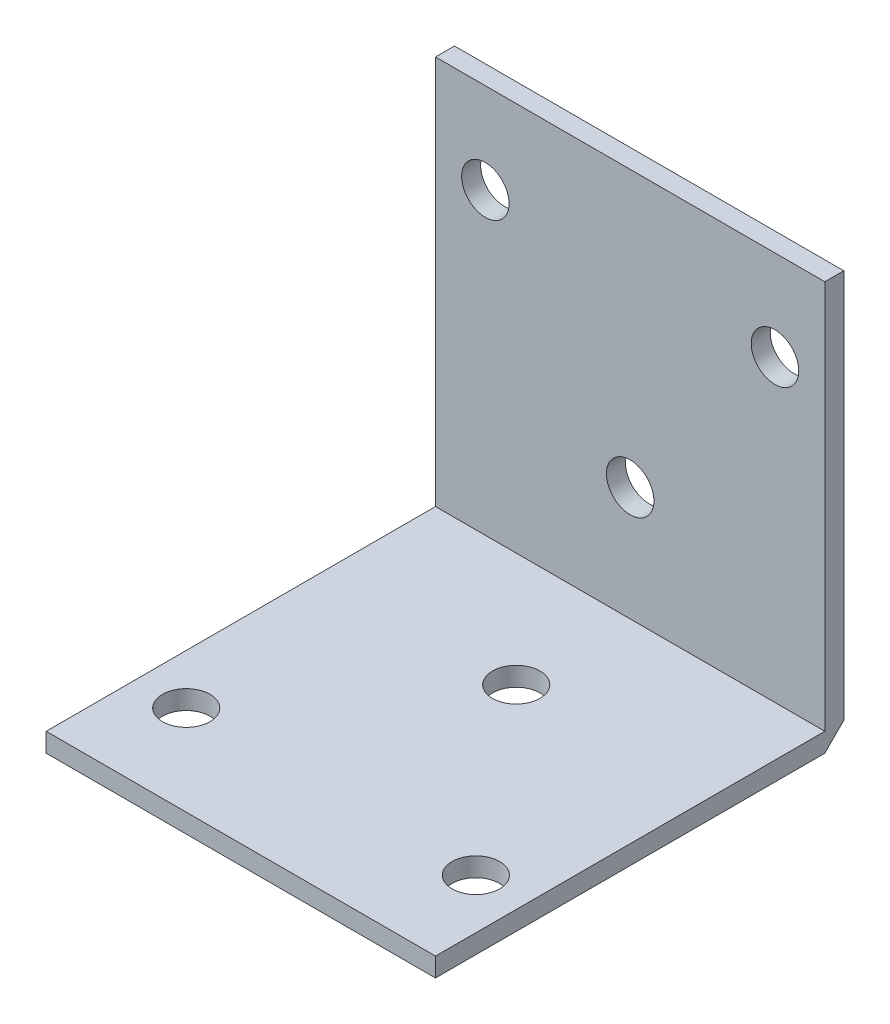
from build123d import *

# Parameters (mm, degrees)
SKETCH_1_W          = 41
SKETCH_1_H          = 41
SKETCH_1_R          = 2.5
EXTRUDE_1_DEPTH     = 2
EXTRUDE_2_DEPTH     = 41
SKETCH_3_R          = 2.5
CUT_EXTRUDE_1_DEPTH = 3


with BuildPart() as part:
    # 草图1 → 凸台-拉伸1 (new body)
    with BuildSketch(Plane(origin=(0, 0, 0), x_dir=(1, 0, 0), z_dir=(0, 1, 0))):
        Rectangle(SKETCH_1_W, SKETCH_1_H)
        with Locations((-15.25, -11)):
            Circle(SKETCH_1_R, mode=Mode.SUBTRACT)
        with Locations((15.25, -11)):
            Circle(SKETCH_1_R, mode=Mode.SUBTRACT)
        with Locations((0, 8.5)):
            Circle(SKETCH_1_R, mode=Mode.SUBTRACT)
    extrude(amount=EXTRUDE_1_DEPTH)

    # 草图2 → 凸台-拉伸2 (add)
    with BuildSketch(Plane.ZY.offset(20.5)):
        Polygon((-22.5, 2), (-20.5, 0), (-20.5, 2), (-20.5, 43), (-22.5, 43), align=None)
    extrude(amount=-EXTRUDE_2_DEPTH)

    # 草图3 → 切除-拉伸1 (cut, through all)
    with BuildSketch(Plane.XY.offset(-20.5)):
        with Locations((-15.25, 33.5)):
            Circle(SKETCH_3_R)
        with Locations((15.25, 33.5)):
            Circle(SKETCH_3_R)
        with Locations((0, 14)):
            Circle(SKETCH_3_R)
    extrude(amount=-CUT_EXTRUDE_1_DEPTH, mode=Mode.SUBTRACT)


solid = part.part
